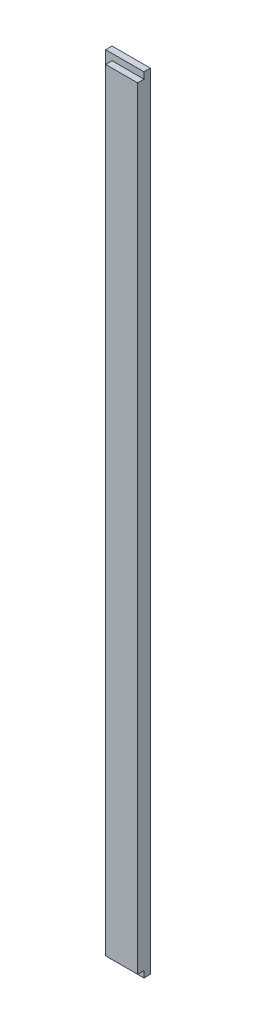
from build123d import *

# Parameters (mm, degrees)
SKETCH1_W           = 60
SKETCH1_H           = 1230
BOSS_EXTRUDE1_DEPTH = 20
CUT_EXTRUDE1_DEPTH  = 10


with BuildPart() as part:
    # Sketch1 → Boss-Extrude1 (new body)
    with BuildSketch(Plane.XY):
        Rectangle(SKETCH1_W, SKETCH1_H)
    extrude(amount=BOSS_EXTRUDE1_DEPTH)

    # Sketch2 → Cut-Extrude1 (cut)
    with BuildSketch(Plane.XY.offset(20)):
        Polygon((30, 605), (-20, 605), (-20, -605), (30, -605), (30, -615), (-30, -615), (-30, 615), (30, 615), align=None)
    extrude(amount=-CUT_EXTRUDE1_DEPTH, mode=Mode.SUBTRACT)


solid = part.part
